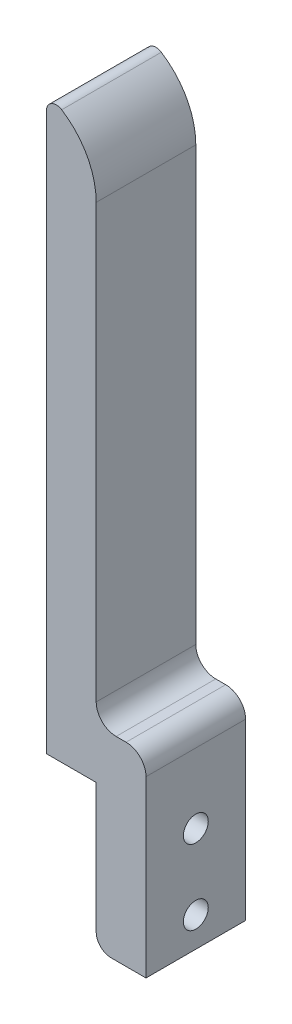
from build123d import *

# Parameters (mm, degrees)
BOSS_EXTRUDE1_DEPTH = 20
SKETCH2_R           = 2.5
CUT_EXTRUDE1_DEPTH  = 21
FILLET1_R           = 3


with BuildPart() as part:
    # Sketch1 → Boss-Extrude1 (new body)
    with BuildSketch(Plane.XY):
        with BuildLine():
            Line((0, 0), (10, 0))
            Line((10, 0), (10, -29))
            Line((10, -29), (20, -29))
            Line((20, -29), (20, 6))
            ThreePointArc((20, 6), (18.828427125, 8.828427125), (16, 10))
            Line((16, 10), (14, 10))
            ThreePointArc((14, 10), (11.171572875, 11.171572875), (10, 14))
            Line((10, 14), (10, 100.857864376))
            ThreePointArc((10, 100.857864376), (8.15587029, 108.063631297), (3.076923077, 113.497615703))
            ThreePointArc((3.076923077, 113.497615703), (1.039231077, 113.566431565), (0, 111.812315526))
            Line((0, 111.812315526), (0, 0))
        make_face()
    extrude(amount=BOSS_EXTRUDE1_DEPTH)

    # Sketch2 → Cut-Extrude1 (cut, through all)
    with BuildSketch(Plane(origin=(20, 0, 0), x_dir=(0, 0, -1), z_dir=(1, 0, 0))):
        with Locations((-10, -8)):
            Circle(SKETCH2_R)
        with Locations((-10, -23)):
            Circle(SKETCH2_R)
    extrude(amount=-CUT_EXTRUDE1_DEPTH, mode=Mode.SUBTRACT)

    # Fillet1
    fillet1_edges = [part.edges().sort_by_distance(p)[0] for p in [
        (10, -29, 10),
    ]]
    fillet(fillet1_edges, radius=FILLET1_R)


solid = part.part
